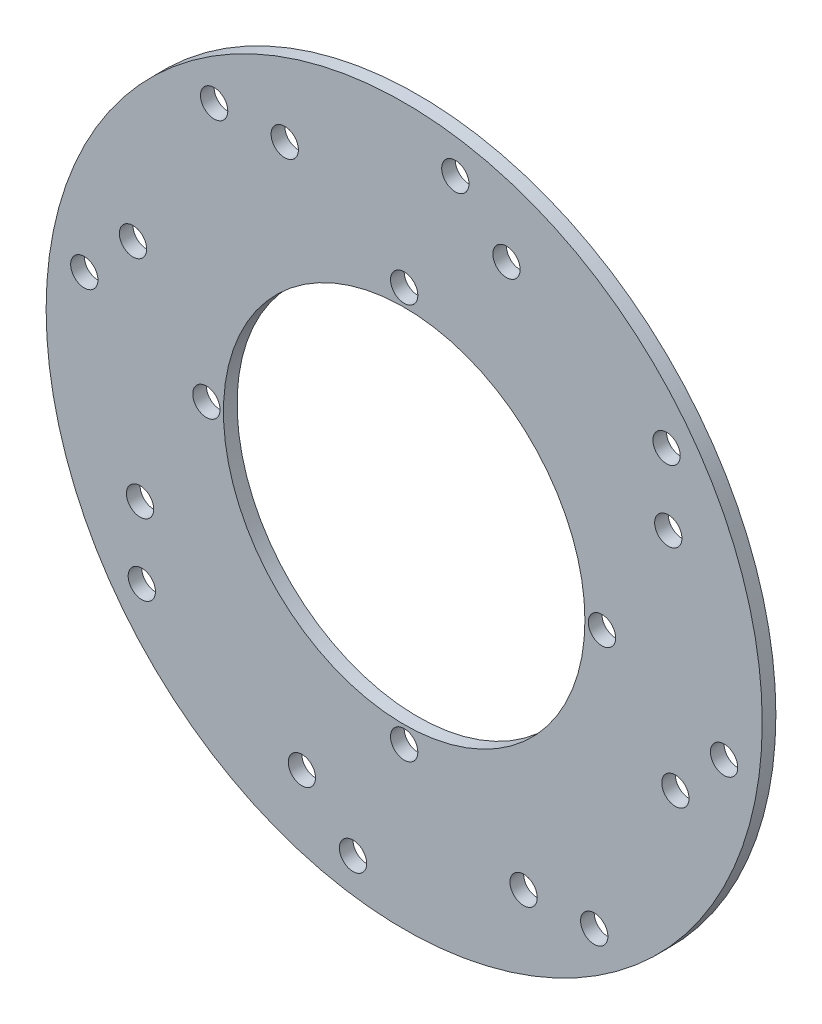
from build123d import *

# Parameters (mm, degrees)
SKETCH1_R           = 105
SKETCH1_R_2         = 53
SKETCH1_R_3         = 4
BOSS_EXTRUDE1_DEPTH = 4


with BuildPart() as part:
    # Sketch1 → Boss-Extrude1 (new body)
    with BuildSketch(Plane.XY):
        Circle(SKETCH1_R)
        Circle(SKETCH1_R_2, mode=Mode.SUBTRACT)
        with Locations((0, 58)):
            Circle(SKETCH1_R_3, mode=Mode.SUBTRACT)
        with Locations((30, 79.529868603)):
            Circle(SKETCH1_R_3, mode=Mode.SUBTRACT)
        with Locations((15, 93.808315196)):
            Circle(SKETCH1_R_3, mode=Mode.SUBTRACT)
        with Locations((58, 0)):
            Circle(SKETCH1_R_3, mode=Mode.SUBTRACT)
        with Locations((0, -58)):
            Circle(SKETCH1_R_3, mode=Mode.SUBTRACT)
        with Locations((-58, 0)):
            Circle(SKETCH1_R_3, mode=Mode.SUBTRACT)
        with Locations((77.449312832, 35.02290596)):
            Circle(SKETCH1_R_3, mode=Mode.SUBTRACT)
        with Locations((79.529868603, -30)):
            Circle(SKETCH1_R_3, mode=Mode.SUBTRACT)
        with Locations((35.02290596, -77.449312832)):
            Circle(SKETCH1_R_3, mode=Mode.SUBTRACT)
        with Locations((-30, -79.529868603)):
            Circle(SKETCH1_R_3, mode=Mode.SUBTRACT)
        with Locations((-77.449312832, -35.02290596)):
            Circle(SKETCH1_R_3, mode=Mode.SUBTRACT)
        with Locations((-79.529868603, 30)):
            Circle(SKETCH1_R_3, mode=Mode.SUBTRACT)
        with Locations((-35.02290596, 77.449312832)):
            Circle(SKETCH1_R_3, mode=Mode.SUBTRACT)
        with Locations((76.939097525, 55.725894089)):
            Circle(SKETCH1_R_3, mode=Mode.SUBTRACT)
        with Locations((93.808315196, -15)):
            Circle(SKETCH1_R_3, mode=Mode.SUBTRACT)
        with Locations((55.725894089, -76.939097525)):
            Circle(SKETCH1_R_3, mode=Mode.SUBTRACT)
        with Locations((-15, -93.808315196)):
            Circle(SKETCH1_R_3, mode=Mode.SUBTRACT)
        with Locations((-76.939097525, -55.725894089)):
            Circle(SKETCH1_R_3, mode=Mode.SUBTRACT)
        with Locations((-93.808315196, 15)):
            Circle(SKETCH1_R_3, mode=Mode.SUBTRACT)
        with Locations((-55.725894089, 76.939097525)):
            Circle(SKETCH1_R_3, mode=Mode.SUBTRACT)
    extrude(amount=BOSS_EXTRUDE1_DEPTH)


solid = part.part
